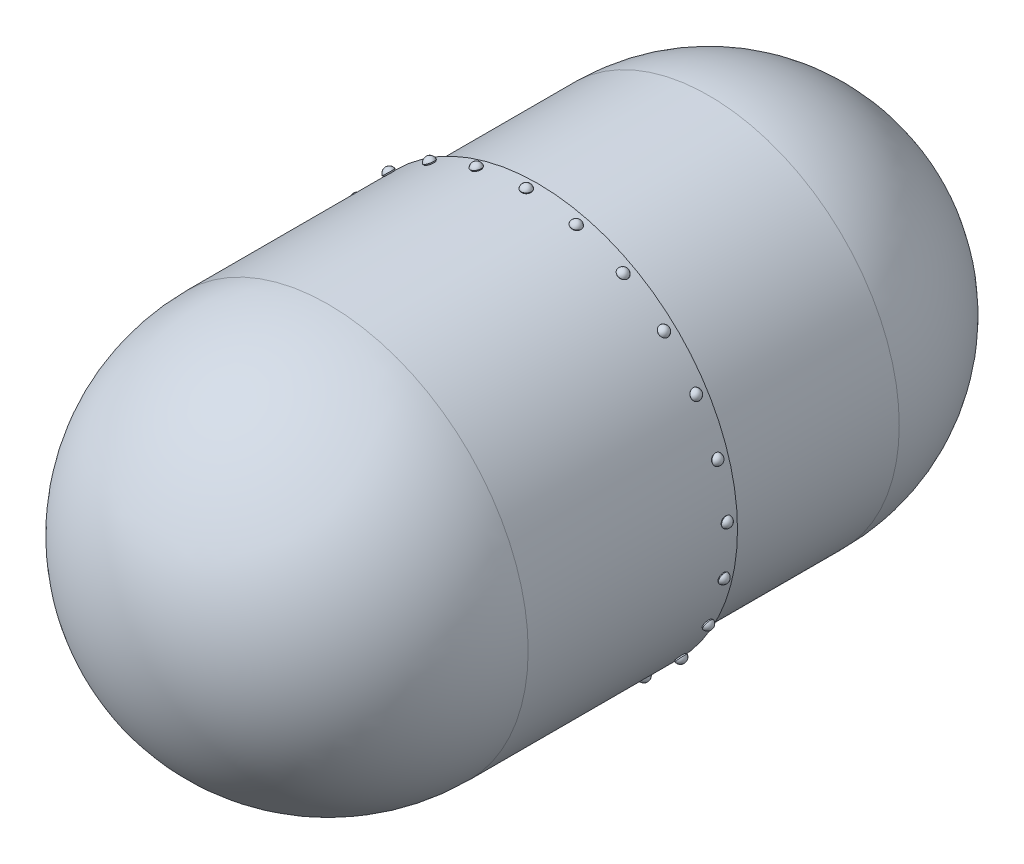
from build123d import *

# Parameters (mm, degrees)
SKETCH1_R                = 1000
SKETCH1_R_2              = 900
BOSS_EXTRUDE1_DEPTH      = 1000
SKETCH2_R                = 1050
SKETCH2_R_2              = 1000
BOSS_EXTRUDE2_DEPTH      = 1000
BOSS_EXTRUDE2_DEPTH_BACK = 100
CIRPATTERN1_COUNT        = 25


with BuildPart() as part:
    # Sketch1 → Boss-Extrude1 (new body)
    with BuildSketch(Plane.XY):
        Circle(SKETCH1_R)
        Circle(SKETCH1_R_2, mode=Mode.SUBTRACT)
    extrude(amount=BOSS_EXTRUDE1_DEPTH)

    # Sketch2 → Boss-Extrude2 (add, two sides)
    with BuildSketch(Plane.XY.offset(1000)) as boss_extrude2_sk:
        Circle(SKETCH2_R)
        Circle(SKETCH2_R_2, mode=Mode.SUBTRACT)
    extrude(amount=BOSS_EXTRUDE2_DEPTH)
    extrude(boss_extrude2_sk.sketch, amount=-BOSS_EXTRUDE2_DEPTH_BACK)

    # Sketch9 → Revolve3 (revolve)
    with BuildSketch(Plane(origin=(0, 0, 0), x_dir=(1, 0, 0), z_dir=(0, 1, 0))):
        with BuildLine():
            Line((0, 0), (1000, 0))
            ThreePointArc((1000, 0), (707.106781187, 707.106781187), (0, 1000))
            Line((0, 1000), (0, 0))
        make_face()
    revolve(axis=Axis((0, 0, -1000), (0, 0, 1)))

    # Sketch10 → Revolve4 (revolve)
    with BuildSketch(Plane(origin=(0, 0, 0), x_dir=(1, 0, 0), z_dir=(0, 1, 0))):
        with BuildLine():
            Line((0, -2000), (1050, -2000))
            ThreePointArc((1050, -2000), (742.462120246, -2742.462120246), (0, -3050))
            Line((0, -3050), (0, -2000))
        make_face()
    revolve(axis=Axis((0, 0, 2000), (0, 0, 1)))


with BuildPart() as body_2:
    # Sketch7 → Revolve1 (revolve)
    with BuildSketch(Plane(origin=(0, 0, 960), x_dir=(-1, 0, 0), z_dir=(0, 0, -1))):
        Polygon((0, 1050), (24, 1050), (27.464101615, 1056), (0, 1056), align=None)
    revolve(axis=Axis((0, 0, 960), (0, 1, 0)))

    # Sketch8 → Revolve2 (revolve)
    with BuildSketch(Plane(origin=(0, 0, 960), x_dir=(-1, 0, 0), z_dir=(0, 0, -1))):
        with BuildLine():
            Line((0, 1079.080403109), (0, 1056))
            Line((0, 1056), (27.464101615, 1056))
            ThreePointArc((27.464101615, 1056), (17.937264878, 1072.544118774), (0, 1079.080403109))
        make_face()
    revolve(axis=Axis((0, 1079.080403109, 960), (0, -1, 0)))


with BuildPart() as cirpattern1_1:
    # CirPattern1: pattern copy
    add(body_2.part.rotate(Axis((0, 0, 900), (0, 0, 1)), 1 * 360 / CIRPATTERN1_COUNT))


with BuildPart() as cirpattern1_2:
    # CirPattern1: pattern copy
    add(body_2.part.rotate(Axis((0, 0, 900), (0, 0, 1)), 2 * 360 / CIRPATTERN1_COUNT))


with BuildPart() as cirpattern1_3:
    # CirPattern1: pattern copy
    add(body_2.part.rotate(Axis((0, 0, 900), (0, 0, 1)), 3 * 360 / CIRPATTERN1_COUNT))


with BuildPart() as cirpattern1_4:
    # CirPattern1: pattern copy
    add(body_2.part.rotate(Axis((0, 0, 900), (0, 0, 1)), 4 * 360 / CIRPATTERN1_COUNT))


with BuildPart() as cirpattern1_5:
    # CirPattern1: pattern copy
    add(body_2.part.rotate(Axis((0, 0, 900), (0, 0, 1)), 5 * 360 / CIRPATTERN1_COUNT))


with BuildPart() as cirpattern1_6:
    # CirPattern1: pattern copy
    add(body_2.part.rotate(Axis((0, 0, 900), (0, 0, 1)), 6 * 360 / CIRPATTERN1_COUNT))


with BuildPart() as cirpattern1_7:
    # CirPattern1: pattern copy
    add(body_2.part.rotate(Axis((0, 0, 900), (0, 0, 1)), 7 * 360 / CIRPATTERN1_COUNT))


with BuildPart() as cirpattern1_8:
    # CirPattern1: pattern copy
    add(body_2.part.rotate(Axis((0, 0, 900), (0, 0, 1)), 8 * 360 / CIRPATTERN1_COUNT))


with BuildPart() as cirpattern1_9:
    # CirPattern1: pattern copy
    add(body_2.part.rotate(Axis((0, 0, 900), (0, 0, 1)), 9 * 360 / CIRPATTERN1_COUNT))


with BuildPart() as cirpattern1_10:
    # CirPattern1: pattern copy
    add(body_2.part.rotate(Axis((0, 0, 900), (0, 0, 1)), 10 * 360 / CIRPATTERN1_COUNT))


with BuildPart() as cirpattern1_11:
    # CirPattern1: pattern copy
    add(body_2.part.rotate(Axis((0, 0, 900), (0, 0, 1)), 11 * 360 / CIRPATTERN1_COUNT))


with BuildPart() as cirpattern1_12:
    # CirPattern1: pattern copy
    add(body_2.part.rotate(Axis((0, 0, 900), (0, 0, 1)), 12 * 360 / CIRPATTERN1_COUNT))


with BuildPart() as cirpattern1_13:
    # CirPattern1: pattern copy
    add(body_2.part.rotate(Axis((0, 0, 900), (0, 0, 1)), 13 * 360 / CIRPATTERN1_COUNT))


with BuildPart() as cirpattern1_14:
    # CirPattern1: pattern copy
    add(body_2.part.rotate(Axis((0, 0, 900), (0, 0, 1)), 14 * 360 / CIRPATTERN1_COUNT))


with BuildPart() as cirpattern1_15:
    # CirPattern1: pattern copy
    add(body_2.part.rotate(Axis((0, 0, 900), (0, 0, 1)), 15 * 360 / CIRPATTERN1_COUNT))


with BuildPart() as cirpattern1_16:
    # CirPattern1: pattern copy
    add(body_2.part.rotate(Axis((0, 0, 900), (0, 0, 1)), 16 * 360 / CIRPATTERN1_COUNT))


with BuildPart() as cirpattern1_17:
    # CirPattern1: pattern copy
    add(body_2.part.rotate(Axis((0, 0, 900), (0, 0, 1)), 17 * 360 / CIRPATTERN1_COUNT))


with BuildPart() as cirpattern1_18:
    # CirPattern1: pattern copy
    add(body_2.part.rotate(Axis((0, 0, 900), (0, 0, 1)), 18 * 360 / CIRPATTERN1_COUNT))


with BuildPart() as cirpattern1_19:
    # CirPattern1: pattern copy
    add(body_2.part.rotate(Axis((0, 0, 900), (0, 0, 1)), 19 * 360 / CIRPATTERN1_COUNT))


with BuildPart() as cirpattern1_20:
    # CirPattern1: pattern copy
    add(body_2.part.rotate(Axis((0, 0, 900), (0, 0, 1)), 20 * 360 / CIRPATTERN1_COUNT))


with BuildPart() as cirpattern1_21:
    # CirPattern1: pattern copy
    add(body_2.part.rotate(Axis((0, 0, 900), (0, 0, 1)), 21 * 360 / CIRPATTERN1_COUNT))


with BuildPart() as cirpattern1_22:
    # CirPattern1: pattern copy
    add(body_2.part.rotate(Axis((0, 0, 900), (0, 0, 1)), 22 * 360 / CIRPATTERN1_COUNT))


with BuildPart() as cirpattern1_23:
    # CirPattern1: pattern copy
    add(body_2.part.rotate(Axis((0, 0, 900), (0, 0, 1)), 23 * 360 / CIRPATTERN1_COUNT))


with BuildPart() as cirpattern1_24:
    # CirPattern1: pattern copy
    add(body_2.part.rotate(Axis((0, 0, 900), (0, 0, 1)), 24 * 360 / CIRPATTERN1_COUNT))


solid = Compound([part.part, body_2.part, cirpattern1_1.part, cirpattern1_2.part, cirpattern1_3.part, cirpattern1_4.part, cirpattern1_5.part, cirpattern1_6.part, cirpattern1_7.part, cirpattern1_8.part, cirpattern1_9.part, cirpattern1_10.part, cirpattern1_11.part, cirpattern1_12.part, cirpattern1_13.part, cirpattern1_14.part, cirpattern1_15.part, cirpattern1_16.part, cirpattern1_17.part, cirpattern1_18.part, cirpattern1_19.part, cirpattern1_20.part, cirpattern1_21.part, cirpattern1_22.part, cirpattern1_23.part, cirpattern1_24.part])
